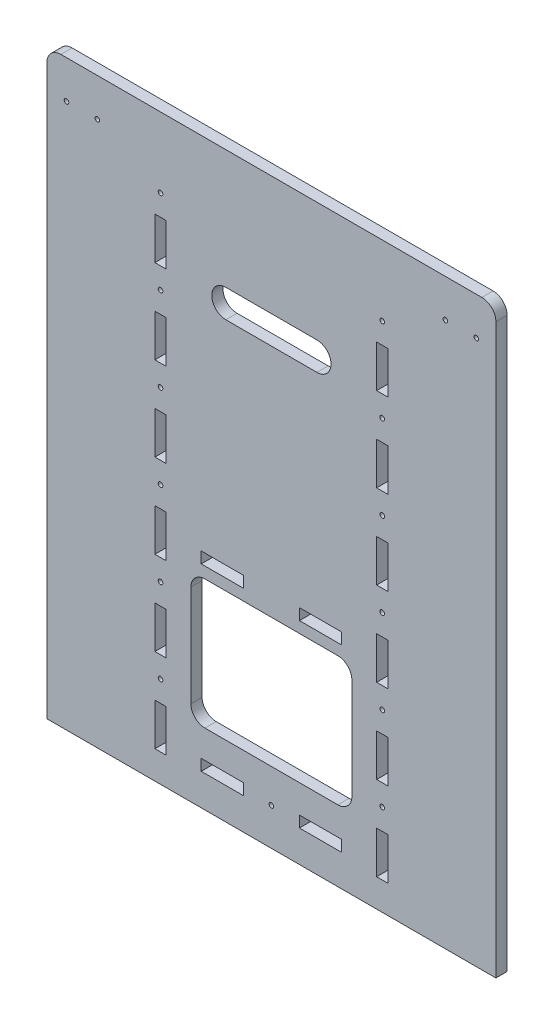
from build123d import *

# Parameters (mm, degrees)
SKETCH1_R           = 1.625
SKETCH1_R_2         = 1.65
SKETCH1_W           = 8
SKETCH1_H           = 30
SKETCH1_W_2         = 30
SKETCH1_H_2         = 8
BOSS_EXTRUDE1_DEPTH = 8
FILLET1_R           = 10
CUT_EXTRUDE1_DEPTH  = 9


with BuildPart() as part:
    # Sketch1 → Boss-Extrude1 (new body)
    with BuildSketch(Plane.XY):
        Polygon((0, 0), (320, 0), (320, 415), (160, 415), (0, 415), align=None)
        with Locations((14, 388)):
            Circle(SKETCH1_R, mode=Mode.SUBTRACT)
        with Locations((36, 388)):
            Circle(SKETCH1_R, mode=Mode.SUBTRACT)
        with Locations((284, 388)):
            Circle(SKETCH1_R, mode=Mode.SUBTRACT)
        with Locations((306, 388)):
            Circle(SKETCH1_R, mode=Mode.SUBTRACT)
        with Locations((81, 65)):
            Circle(SKETCH1_R_2, mode=Mode.SUBTRACT)
        with Locations((239, 65)):
            Circle(SKETCH1_R_2, mode=Mode.SUBTRACT)
        with Locations((81, 125)):
            Circle(SKETCH1_R_2, mode=Mode.SUBTRACT)
        with Locations((239, 125)):
            Circle(SKETCH1_R_2, mode=Mode.SUBTRACT)
        with Locations((81, 185)):
            Circle(SKETCH1_R_2, mode=Mode.SUBTRACT)
        with Locations((239, 185)):
            Circle(SKETCH1_R_2, mode=Mode.SUBTRACT)
        with Locations((81, 245)):
            Circle(SKETCH1_R_2, mode=Mode.SUBTRACT)
        with Locations((239, 245)):
            Circle(SKETCH1_R_2, mode=Mode.SUBTRACT)
        with Locations((81, 305)):
            Circle(SKETCH1_R_2, mode=Mode.SUBTRACT)
        with Locations((239, 305)):
            Circle(SKETCH1_R_2, mode=Mode.SUBTRACT)
        with Locations((81, 365)):
            Circle(SKETCH1_R_2, mode=Mode.SUBTRACT)
        with Locations((239, 365)):
            Circle(SKETCH1_R_2, mode=Mode.SUBTRACT)
        with Locations((160, 26.566938385)):
            Circle(SKETCH1_R_2, mode=Mode.SUBTRACT)
        with BuildLine():
            Line((112.646025267, 142.602367126), (207.353974733, 142.602367126))
            ThreePointArc((207.353974733, 142.602367126), (214.425042545, 139.673434938), (217.353974733, 132.602367126))
            Line((217.353974733, 132.602367126), (217.353974733, 60.566938385))
            ThreePointArc((217.353974733, 60.566938385), (214.425042545, 53.495870573), (207.353974733, 50.566938385))
            Line((207.353974733, 50.566938385), (112.646025267, 50.566938385))
            ThreePointArc((112.646025267, 50.566938385), (105.574957455, 53.495870573), (102.646025267, 60.566938385))
            Line((102.646025267, 60.566938385), (102.646025267, 132.602367126))
            ThreePointArc((102.646025267, 132.602367126), (105.574957455, 139.673434938), (112.646025267, 142.602367126))
        make_face(mode=Mode.SUBTRACT)
        with Locations((81, 35)):
            Rectangle(SKETCH1_W, SKETCH1_H, mode=Mode.SUBTRACT)
        with Locations((195, 26.566938385)):
            Rectangle(SKETCH1_W_2, SKETCH1_H_2, mode=Mode.SUBTRACT)
        with Locations((125, 26.566938385)):
            Rectangle(SKETCH1_W_2, SKETCH1_H_2, mode=Mode.SUBTRACT)
        with Locations((125, 154.566938385)):
            Rectangle(SKETCH1_W_2, SKETCH1_H_2, mode=Mode.SUBTRACT)
        with Locations((195, 154.566938385)):
            Rectangle(SKETCH1_W_2, SKETCH1_H_2, mode=Mode.SUBTRACT)
        with Locations((239, 35)):
            Rectangle(SKETCH1_W, SKETCH1_H, mode=Mode.SUBTRACT)
        with Locations((81, 95)):
            Rectangle(SKETCH1_W, SKETCH1_H, mode=Mode.SUBTRACT)
        with Locations((239, 95)):
            Rectangle(SKETCH1_W, SKETCH1_H, mode=Mode.SUBTRACT)
        with Locations((81, 155)):
            Rectangle(SKETCH1_W, SKETCH1_H, mode=Mode.SUBTRACT)
        with Locations((239, 155)):
            Rectangle(SKETCH1_W, SKETCH1_H, mode=Mode.SUBTRACT)
        with Locations((81, 215)):
            Rectangle(SKETCH1_W, SKETCH1_H, mode=Mode.SUBTRACT)
        with Locations((239, 215)):
            Rectangle(SKETCH1_W, SKETCH1_H, mode=Mode.SUBTRACT)
        with Locations((81, 275)):
            Rectangle(SKETCH1_W, SKETCH1_H, mode=Mode.SUBTRACT)
        with Locations((239, 275)):
            Rectangle(SKETCH1_W, SKETCH1_H, mode=Mode.SUBTRACT)
        with Locations((81, 335)):
            Rectangle(SKETCH1_W, SKETCH1_H, mode=Mode.SUBTRACT)
        with Locations((239, 335)):
            Rectangle(SKETCH1_W, SKETCH1_H, mode=Mode.SUBTRACT)
    extrude(amount=BOSS_EXTRUDE1_DEPTH)

    # Fillet1
    fillet1_edges = [part.edges().sort_by_distance(p)[0] for p in [
        (0, 415, 4),
        (320, 415, 4),
    ]]
    fillet(fillet1_edges, radius=FILLET1_R)

    # Sketch2 → Cut-Extrude1 (cut, through all)
    with BuildSketch(Plane(origin=(0, 0, 0), x_dir=(-1, 0, 0), z_dir=(0, 0, -1))):
        with BuildLine():
            Line((-192.5, 330), (-127.5, 330))
            ThreePointArc((-127.5, 330), (-117.5, 320), (-127.5, 310))
            Line((-127.5, 310), (-192.5, 310))
            ThreePointArc((-192.5, 310), (-202.5, 320), (-192.5, 330))
        make_face()
    extrude(amount=-CUT_EXTRUDE1_DEPTH, mode=Mode.SUBTRACT)


solid = part.part
